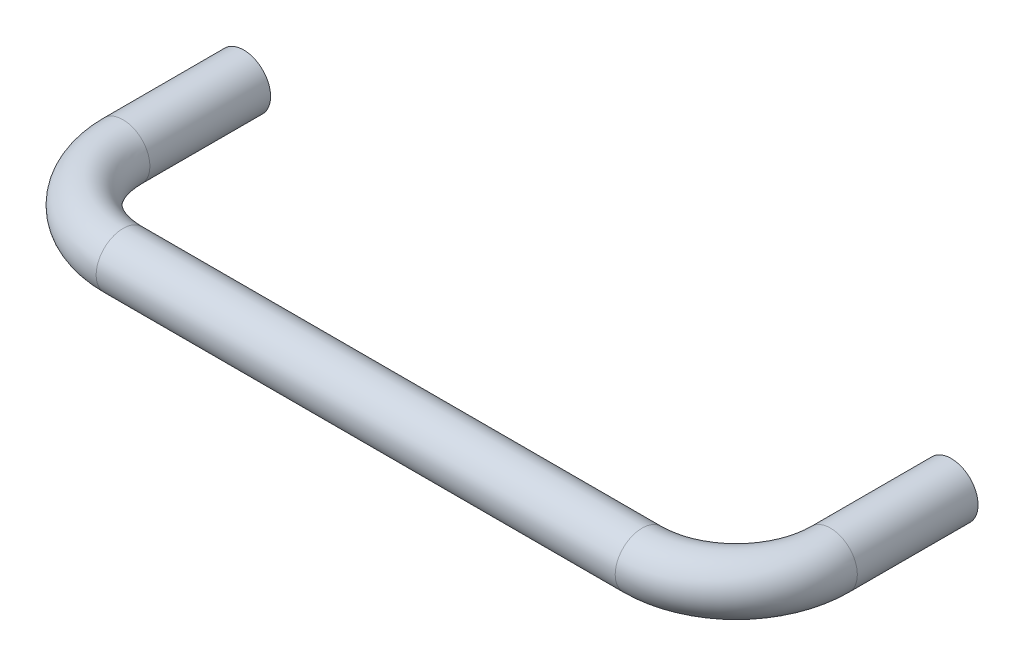
from build123d import *

# Parameters (mm, degrees)
SKETCH2_R                     = 4.7625
LOCATION_START                = -5.08
SKETCH4_R                     = 1.524
LOCATION_HOLE_OTHER_WAY_DEPTH = 81.074387678


with BuildPart() as part:
    # Handle: sweep along a path in Sketch3
    with BuildLine(Plane(origin=(0, 0, 0), x_dir=(1, 0, 0), z_dir=(0, 1, 0))) as handle_path:
        Line((62.70625, 19.05), (62.70625, -2.3495))
        ThreePointArc((62.70625, -2.3495), (57.814786799, -14.158536799), (46.00575, -19.05))
        Line((46.00575, -19.05), (-46.00575, -19.05))
        ThreePointArc((-46.00575, -19.05), (-57.814786799, -14.158536799), (-62.70625, -2.3495))
        Line((-62.70625, -2.3495), (-62.70625, 19.05))
    # Sketch2 → Handle (sweep)
    with BuildSketch(Plane.XY.offset(-19.05)):
        with Locations((-62.70625, 0)):
            Circle(SKETCH2_R)
    sweep(path=handle_path.line)

    # Location Hole cone 1 section (through the dimple's axis) → Location Hole (revolve, cut)
    with BuildSketch(Plane(origin=(-62.70625, 0, -13.97), x_dir=(0, 1, 0), z_dir=(1, 0, 0))):
        Polygon((0, 0), (1.524, 0), (0, 0.87988181), align=None)
    revolve(axis=Axis((-62.70625, 0, -13.97), (0, 0, 1)), mode=Mode.SUBTRACT)

    # Location Hole cone 2 section (through the dimple's axis) → Location Hole cone 2 (revolve, cut)
    with BuildSketch(Plane(origin=(62.70625, 0, -13.97), x_dir=(0, 1, 0), z_dir=(1, 0, 0))):
        Polygon((0, 0), (1.524, 0), (0, 0.87988181), align=None)
    revolve(axis=Axis((62.70625, 0, -13.97), (0, 0, 1)), mode=Mode.SUBTRACT)

    # Sketch4 → Location Hole other way (cut)
    with BuildSketch(Plane(origin=(0, 0, -19.05), x_dir=(-1, 0, 0), z_dir=(0, 0, -1)).offset(LOCATION_START)):
        with Locations((62.70625, 0)):
            Circle(SKETCH4_R)
        with Locations((-62.70625, 0)):
            Circle(SKETCH4_R)
    extrude(amount=LOCATION_HOLE_OTHER_WAY_DEPTH, mode=Mode.SUBTRACT)


solid = part.part
